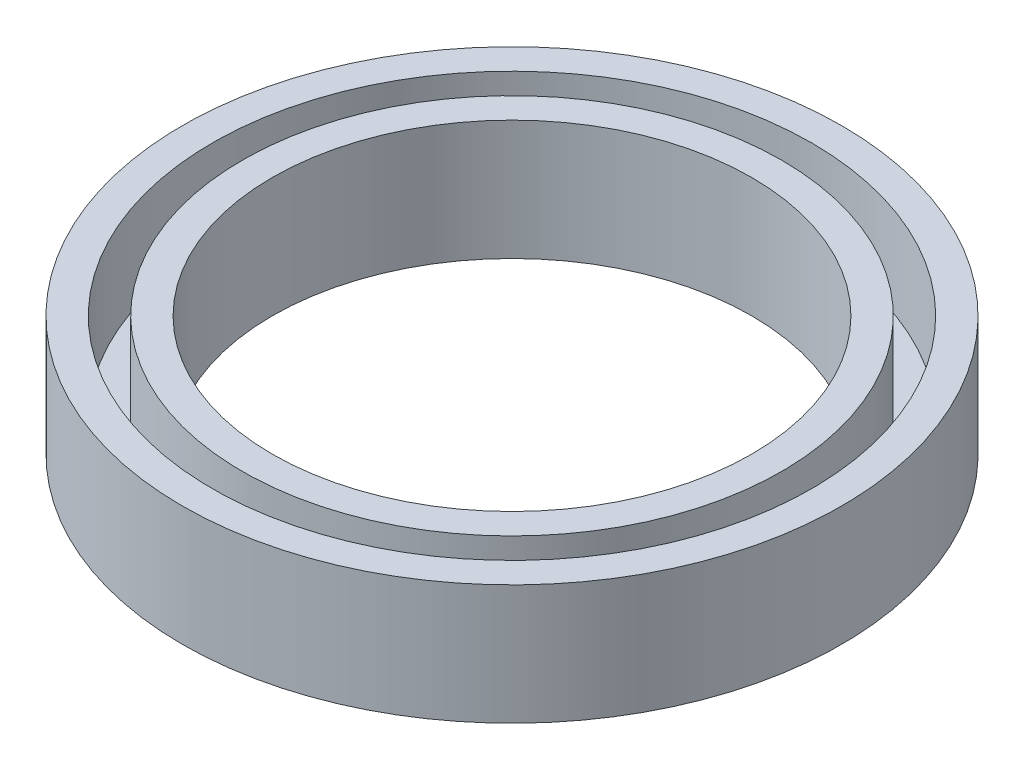
from build123d import *


with BuildPart() as part:
    # Sketch1 → Revolve1 (revolve)
    with BuildSketch(Plane.XY):
        Polygon((-8.73125, 3.175), (-8.73125, 0), (-6.35, 0), (-6.35, 3.175), (-7.14375, 3.175), (-7.14375, 0.79375), (-7.9375, 0.79375), (-7.9375, 3.175), align=None)
    revolve(axis=Axis((0, 0, 0), (0, 1, 0)))


solid = part.part
